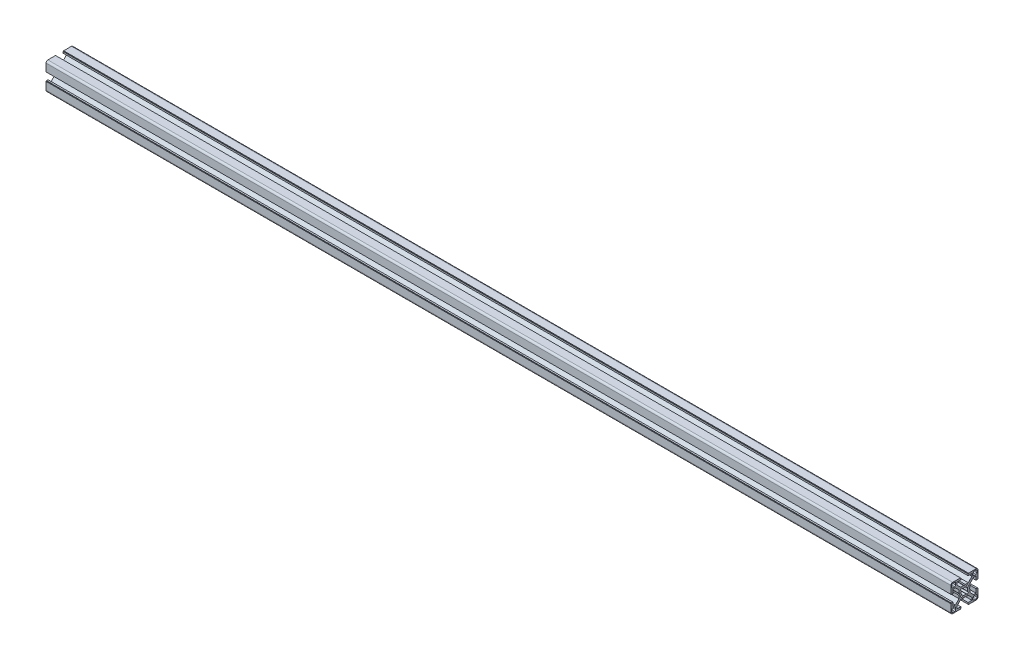
from build123d import *

# Parameters (mm, degrees)
ESTRUSIONE_ESTRUSIONE1_DEPTH = 1000


with BuildPart() as part:
    # Schizzo1 → Estrusione-Estrusione1 (new body)
    with BuildSketch(Plane(origin=(0, 0, 0), x_dir=(0, -1, 0), z_dir=(-1, 0, 0))):
        with BuildLine():
            Line((-10.05312229, 8.25), (-6, 4.19687771))
            Line((-6, 4.19687771), (-6, 0.91961524))
            Line((-6, 0.91961524), (-5.469059893, -2e-09))
            Line((-5.469059893, -2e-09), (-6, -0.91961524))
            Line((-6, -0.91961524), (-6, -4.19687771))
            Line((-6, -4.19687771), (-10.05312229, -8.25))
            Line((-10.05312229, -8.25), (-12.80312305, -8.25))
            Line((-12.80312305, -8.25), (-12.8, -4))
            Line((-12.8, -4), (-14.5, -4))
            Line((-14.5, -4), (-14.5, -4.5))
            Line((-14.5, -4.5), (-15, -4.5))
            Line((-15, -4.5), (-15, -13))
            ThreePointArc((-15, -13), (-14.414213562, -14.414213562), (-13, -15))
            Line((-13, -15), (-4.5, -15))
            Line((-4.5, -15), (-4.5, -14.5))
            Line((-4.5, -14.5), (-4, -14.5))
            Line((-4, -14.5), (-4, -12.8))
            Line((-4, -12.8), (-8.25, -12.80312305))
            Line((-8.25, -12.80312305), (-8.25, -10.05312229))
            Line((-8.25, -10.05312229), (-4.19687771, -6))
            Line((-4.19687771, -6), (-0.91961524, -6))
            Line((-0.91961524, -6), (2e-09, -5.469059893))
            Line((2e-09, -5.469059893), (0.91961524, -6))
            Line((0.91961524, -6), (4.19687771, -6))
            Line((4.19687771, -6), (8.25, -10.05312229))
            Line((8.25, -10.05312229), (8.25, -12.80312305))
            Line((8.25, -12.80312305), (4, -12.8))
            Line((4, -12.8), (4, -14.5))
            Line((4, -14.5), (4.5, -14.5))
            Line((4.5, -14.5), (4.5, -15))
            Line((4.5, -15), (13, -15))
            ThreePointArc((13, -15), (14.414213562, -14.414213562), (15, -13))
            Line((15, -13), (15, -4.5))
            Line((15, -4.5), (14.5, -4.5))
            Line((14.5, -4.5), (14.5, -4))
            Line((14.5, -4), (12.8, -4))
            Line((12.8, -4), (12.80312305, -8.25))
            Line((12.80312305, -8.25), (10.05312229, -8.25))
            Line((10.05312229, -8.25), (6, -4.19687771))
            Line((6, -4.19687771), (6, -0.91961524))
            Line((6, -0.91961524), (5.469059893, -2e-09))
            Line((5.469059893, -2e-09), (6, 0.91961524))
            Line((6, 0.91961524), (6, 4.19687771))
            Line((6, 4.19687771), (10.05312229, 8.25))
            Line((10.05312229, 8.25), (12.80312305, 8.25))
            Line((12.80312305, 8.25), (12.8, 4))
            Line((12.8, 4), (14.5, 4))
            Line((14.5, 4), (14.5, 4.5))
            Line((14.5, 4.5), (15, 4.5))
            Line((15, 4.5), (15, 13))
            ThreePointArc((15, 13), (14.414213562, 14.414213562), (13, 15))
            Line((13, 15), (4.5, 15))
            Line((4.5, 15), (4.5, 14.5))
            Line((4.5, 14.5), (4, 14.5))
            Line((4, 14.5), (4, 12.8))
            Line((4, 12.8), (8.25, 12.80312305))
            Line((8.25, 12.80312305), (8.25, 10.05312229))
            Line((8.25, 10.05312229), (4.19687771, 6))
            Line((4.19687771, 6), (0.91961524, 6))
            Line((0.91961524, 6), (2e-09, 5.469059893))
            Line((2e-09, 5.469059893), (-0.91961524, 6))
            Line((-0.91961524, 6), (-4.19687771, 6))
            Line((-4.19687771, 6), (-8.25, 10.05312229))
            Line((-8.25, 10.05312229), (-8.25, 12.80312305))
            Line((-8.25, 12.80312305), (-4, 12.8))
            Line((-4, 12.8), (-4, 14.5))
            Line((-4, 14.5), (-4.5, 14.5))
            Line((-4.5, 14.5), (-4.5, 15))
            Line((-4.5, 15), (-13, 15))
            ThreePointArc((-13, 15), (-14.414213562, 14.414213562), (-15, 13))
            Line((-15, 13), (-15, 4.5))
            Line((-15, 4.5), (-14.5, 4.5))
            Line((-14.5, 4.5), (-14.5, 4))
            Line((-14.5, 4), (-12.8, 4))
            Line((-12.8, 4), (-12.80312305, 8.25))
            Line((-12.80312305, 8.25), (-10.05312229, 8.25))
        make_face()
        with BuildLine():
            Line((-3.117157854, 4.531371416), (-1.616767222, 3.272394195))
            ThreePointArc((-1.616767222, 3.272394195), (5e-09, 3.650000002), (1.616767231, 3.272394191))
            Line((1.616767231, 3.272394191), (3.117157862, 4.531371411))
            ThreePointArc((3.117157862, 4.531371411), (3.889087302, 3.889087292), (4.53137142, 3.11715785))
            Line((4.53137142, 3.11715785), (3.272394197, 1.616767219))
            ThreePointArc((3.272394197, 1.616767219), (3.650000003, -4e-09), (3.272394193, -1.616767225))
            Line((3.272394193, -1.616767225), (4.531371415, -3.117157856))
            ThreePointArc((4.531371415, -3.117157856), (3.889087297, -3.889087296), (3.117157857, -4.531371414))
            Line((3.117157857, -4.531371414), (1.616767227, -3.272394192))
            ThreePointArc((1.616767227, -3.272394192), (5e-09, -3.650000002), (-1.616767217, -3.272394197))
            Line((-1.616767217, -3.272394197), (-3.117157849, -4.531371419))
            ThreePointArc((-3.117157849, -4.531371419), (-3.889087291, -3.889087301), (-4.531371411, -3.117157861))
            Line((-4.531371411, -3.117157861), (-3.27239419, -1.61676723))
            ThreePointArc((-3.27239419, -1.61676723), (-3.650000002, -5e-09), (-3.272394194, 1.616767222))
            Line((-3.272394194, 1.616767222), (-4.531371416, 3.117157855))
            ThreePointArc((-4.531371416, 3.117157855), (-3.889087296, 3.889087297), (-3.117157854, 4.531371416))
        make_face(mode=Mode.SUBTRACT)
        with BuildLine():
            Line((12.85, 9.7), (10.7, 9.7))
            ThreePointArc((10.7, 9.7), (9.992893219, 9.992893219), (9.7, 10.7))
            Line((9.7, 10.7), (9.7, 12.85))
            ThreePointArc((9.7, 12.85), (9.992893219, 13.557106781), (10.7, 13.85))
            Line((10.7, 13.85), (12.85, 13.85))
            ThreePointArc((12.85, 13.85), (13.557106781, 13.557106781), (13.85, 12.85))
            Line((13.85, 12.85), (13.85, 10.7))
            ThreePointArc((13.85, 10.7), (13.557106781, 9.992893219), (12.85, 9.7))
        make_face(mode=Mode.SUBTRACT)
        with BuildLine():
            Line((-9.7, 12.85), (-9.7, 10.7))
            ThreePointArc((-9.7, 10.7), (-9.992893219, 9.992893219), (-10.7, 9.7))
            Line((-10.7, 9.7), (-12.85, 9.7))
            ThreePointArc((-12.85, 9.7), (-13.557106781, 9.992893219), (-13.85, 10.7))
            Line((-13.85, 10.7), (-13.85, 12.85))
            ThreePointArc((-13.85, 12.85), (-13.557106781, 13.557106781), (-12.85, 13.85))
            Line((-12.85, 13.85), (-10.7, 13.85))
            ThreePointArc((-10.7, 13.85), (-9.992893219, 13.557106781), (-9.7, 12.85))
        make_face(mode=Mode.SUBTRACT)
        with BuildLine():
            Line((-12.85, -9.7), (-10.7, -9.7))
            ThreePointArc((-10.7, -9.7), (-9.992893219, -9.992893219), (-9.7, -10.7))
            Line((-9.7, -10.7), (-9.7, -12.85))
            ThreePointArc((-9.7, -12.85), (-9.992893219, -13.557106781), (-10.7, -13.85))
            Line((-10.7, -13.85), (-12.85, -13.85))
            ThreePointArc((-12.85, -13.85), (-13.557106781, -13.557106781), (-13.85, -12.85))
            Line((-13.85, -12.85), (-13.85, -10.7))
            ThreePointArc((-13.85, -10.7), (-13.557106781, -9.992893219), (-12.85, -9.7))
        make_face(mode=Mode.SUBTRACT)
        with BuildLine():
            Line((9.7, -12.85), (9.7, -10.7))
            ThreePointArc((9.7, -10.7), (9.992893219, -9.992893219), (10.7, -9.7))
            Line((10.7, -9.7), (12.85, -9.7))
            ThreePointArc((12.85, -9.7), (13.557106781, -9.992893219), (13.85, -10.7))
            Line((13.85, -10.7), (13.85, -12.85))
            ThreePointArc((13.85, -12.85), (13.557106781, -13.557106781), (12.85, -13.85))
            Line((12.85, -13.85), (10.7, -13.85))
            ThreePointArc((10.7, -13.85), (9.992893219, -13.557106781), (9.7, -12.85))
        make_face(mode=Mode.SUBTRACT)
    extrude(amount=-ESTRUSIONE_ESTRUSIONE1_DEPTH)


solid = part.part
